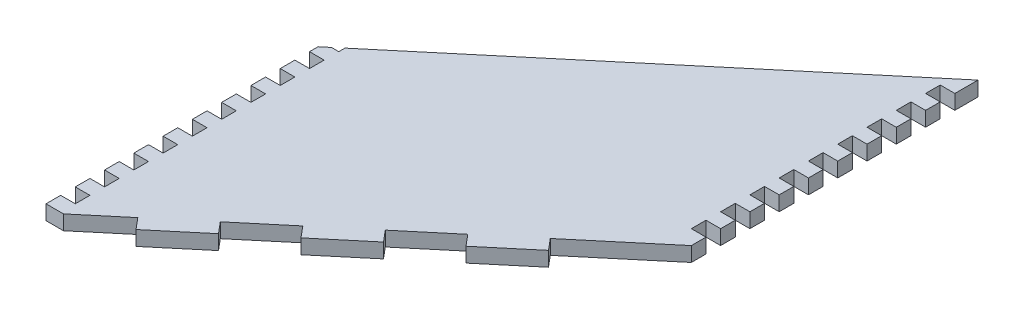
from build123d import *

# Parameters (mm, degrees)
BOSS_EXTRUDE1_DEPTH = 6.35
CUT_EXTRUDE1_DEPTH  = 7.35
SKETCH3_W           = 6.35
SKETCH3_H           = 6.35
CUT_EXTRUDE2_DEPTH  = 7.35
SKETCH4_W           = 12.7
SKETCH4_H           = 6.35
SKETCH4_W_2         = 6.35
CUT_EXTRUDE3_DEPTH  = 7.35


with BuildPart() as part:
    # Sketch1 → Boss-Extrude1 (new body)
    with BuildSketch(Plane(origin=(0, 0, 0), x_dir=(1, 0, 0), z_dir=(0, 1, 0))):
        Polygon((-45.492088676, -38.013071454), (-45.492088676, 94.616309142), (110.168142166, 225.23075143), (110.168142166, 92.601370834), align=None)
    extrude(amount=BOSS_EXTRUDE1_DEPTH)

    # Sketch2 → Cut-Extrude1 (cut, through all)
    with BuildSketch(Plane(origin=(0, 6.35, 0), x_dir=(1, 0, 0), z_dir=(0, 1, 0))):
        Polygon((-45.492088676, -38.013071454), (-16.305795393, -13.522863525), (-20.387496714, -8.658481312), (-49.573789997, -33.148689241), align=None)
        Polygon((-0.929967859, 7.668323974), (3.151733462, 2.803941761), (22.609262318, 19.130747047), (18.527560996, 23.995129261), align=None)
        Polygon((37.985089851, 40.321934547), (42.066791173, 35.457552333), (61.524320028, 51.784357619), (57.442618706, 56.648739833), align=None)
        Polygon((80.981848883, 68.111162905), (115.03252438, 96.683072155), (110.950823058, 101.547454369), (76.900147562, 72.975545119), align=None)
    extrude(amount=-CUT_EXTRUDE1_DEPTH, mode=Mode.SUBTRACT)

    # Sketch3 → Cut-Extrude2 (cut, through all)
    with BuildSketch(Plane(origin=(0, 6.35, 0), x_dir=(1, 0, 0), z_dir=(0, 1, 0))):
        with Locations((106.993142166, 135.815707121)):
            Rectangle(SKETCH3_W, SKETCH3_H)
        with Locations((106.993142166, 123.115707121)):
            Rectangle(SKETCH3_W, SKETCH3_H)
        with Locations((106.993142166, 110.415707121)):
            Rectangle(SKETCH3_W, SKETCH3_H)
        with Locations((106.993142166, 148.515707121)):
            Rectangle(SKETCH3_W, SKETCH3_H)
        with Locations((106.993142166, 173.915707121)):
            Rectangle(SKETCH3_W, SKETCH3_H)
        with Locations((106.993142166, 186.615707121)):
            Rectangle(SKETCH3_W, SKETCH3_H)
        with Locations((106.993142166, 212.015707121)):
            Rectangle(SKETCH3_W, SKETCH3_H)
        with Locations((106.993142166, 161.215707121)):
            Rectangle(SKETCH3_W, SKETCH3_H)
        with Locations((106.993142166, 199.315707121)):
            Rectangle(SKETCH3_W, SKETCH3_H)
    extrude(amount=-CUT_EXTRUDE2_DEPTH, mode=Mode.SUBTRACT)

    # Sketch4 → Cut-Extrude3 (cut, through all)
    with BuildSketch(Plane(origin=(0, 6.35, 0), x_dir=(1, 0, 0), z_dir=(0, 1, 0))):
        with Locations((-39.142088676, -26.548735167)):
            Rectangle(SKETCH4_W, SKETCH4_H)
        with Locations((-42.317088676, -1.148735167)):
            Rectangle(SKETCH4_W_2, SKETCH4_H)
        with Locations((-42.317088676, -13.848735167)):
            Rectangle(SKETCH4_W_2, SKETCH4_H)
        with Locations((-42.317088676, 11.551264833)):
            Rectangle(SKETCH4_W_2, SKETCH4_H)
        with Locations((-42.317088676, 24.251264833)):
            Rectangle(SKETCH4_W_2, SKETCH4_H)
        with Locations((-42.317088676, 36.951264833)):
            Rectangle(SKETCH4_W_2, SKETCH4_H)
        with Locations((-42.317088676, 49.651264833)):
            Rectangle(SKETCH4_W_2, SKETCH4_H)
        with Locations((-42.317088676, 62.351264833)):
            Rectangle(SKETCH4_W_2, SKETCH4_H)
        with Locations((-42.317088676, 75.051264833)):
            Rectangle(SKETCH4_W_2, SKETCH4_H)
        with Locations((-42.317088676, 87.751264833)):
            Rectangle(SKETCH4_W_2, SKETCH4_H)
        with Locations((-42.317088676, 100.451264833)):
            Rectangle(SKETCH4_W_2, SKETCH4_H)
    extrude(amount=-CUT_EXTRUDE3_DEPTH, mode=Mode.SUBTRACT)


solid = part.part
